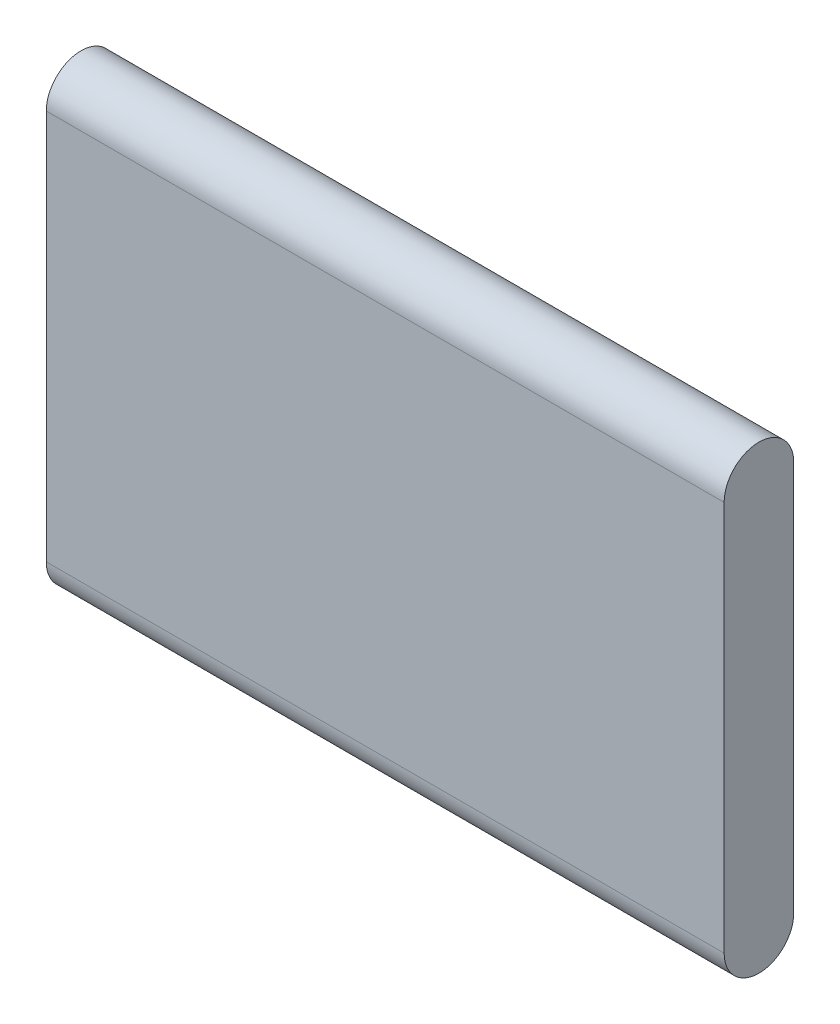
from build123d import *

# Parameters (mm, degrees)
BOSS_EXTRUDE1_DEPTH = 355.6


with BuildPart() as part:
    # Sketch1 → Boss-Extrude1 (new body, symmetric)
    with BuildSketch(Plane(origin=(0, 0, 0), x_dir=(0, 0, -1), z_dir=(1, 0, 0))):
        with BuildLine():
            Line((-36.5125, 204.7875), (-36.5125, -204.7875))
            ThreePointArc((-36.5125, -204.7875), (0, -241.3), (36.5125, -204.7875))
            Line((36.5125, -204.7875), (36.5125, 204.7875))
            ThreePointArc((36.5125, 204.7875), (0, 241.3), (-36.5125, 204.7875))
        make_face()
    extrude(amount=BOSS_EXTRUDE1_DEPTH, both=True)


solid = part.part
